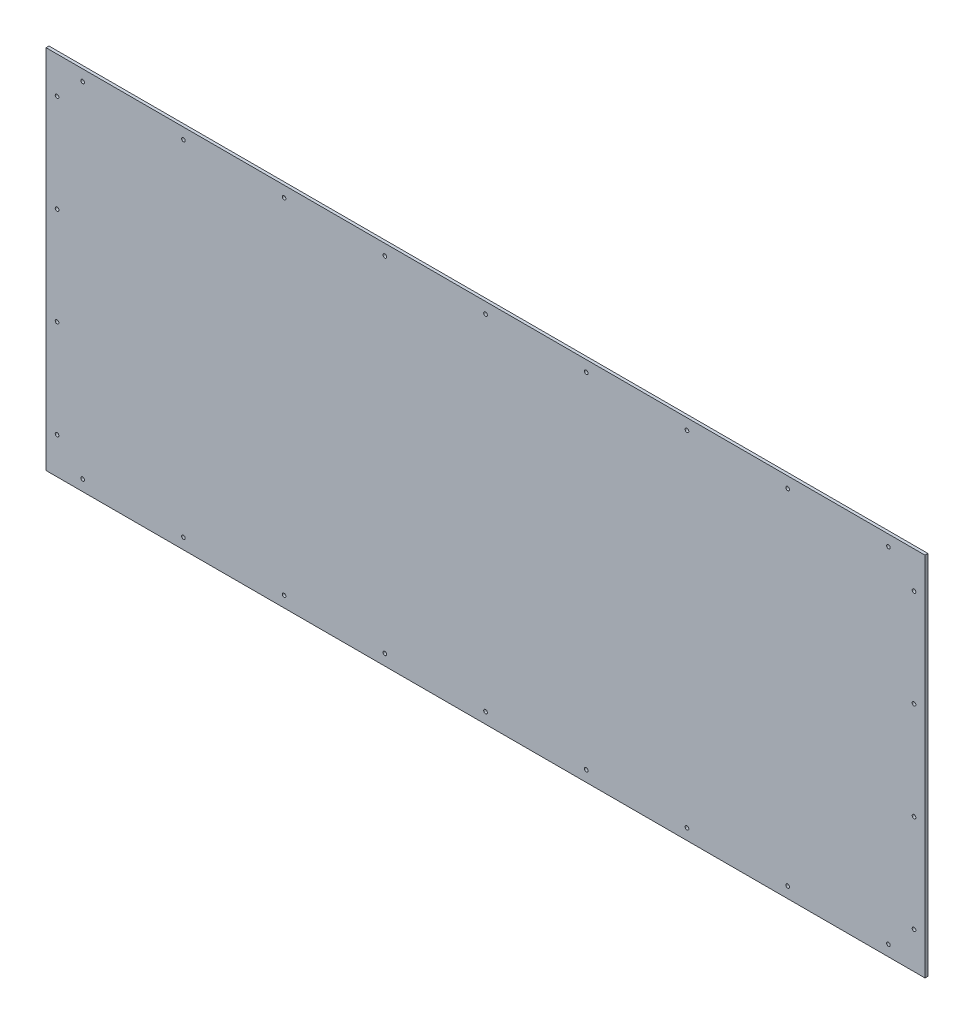
from build123d import *

# Parameters (mm, degrees)
CROQUIS2_W              = 600
CROQUIS2_H              = 250
SALIENTE_EXTRUIR1_DEPTH = 2
CROQUIS5_R              = 1.25
CORTAR_EXTRUIR3_DEPTH   = 3


with BuildPart() as part:
    # Croquis2 → Saliente-Extruir1 (new body)
    with BuildSketch(Plane.XY):
        Rectangle(CROQUIS2_W, CROQUIS2_H)
    extrude(amount=SALIENTE_EXTRUIR1_DEPTH)

    # Croquis5 → Cortar-Extruir3 (cut, through all)
    with BuildSketch(Plane.XY):
        with Locations((-292.5, 100)):
            Circle(CROQUIS5_R)
        with Locations((-292.5, -100)):
            Circle(CROQUIS5_R)
        with Locations((-292.5, 33.333333333)):
            Circle(CROQUIS5_R)
        with Locations((-292.5, -33.333333333)):
            Circle(CROQUIS5_R)
        with Locations((292.5, -33.333333333)):
            Circle(CROQUIS5_R)
        with Locations((292.5, 33.333333333)):
            Circle(CROQUIS5_R)
        with Locations((292.5, -100)):
            Circle(CROQUIS5_R)
        with Locations((292.5, 100)):
            Circle(CROQUIS5_R)
        with Locations((-275, 117.5)):
            Circle(CROQUIS5_R)
        with Locations((-206.25, 117.5)):
            Circle(CROQUIS5_R)
        with Locations((-137.5, 117.5)):
            Circle(CROQUIS5_R)
        with Locations((-68.75, 117.5)):
            Circle(CROQUIS5_R)
        with Locations((68.75, 117.5)):
            Circle(CROQUIS5_R)
        with Locations((137.5, 117.5)):
            Circle(CROQUIS5_R)
        with Locations((206.25, 117.5)):
            Circle(CROQUIS5_R)
        with Locations((275, 117.5)):
            Circle(CROQUIS5_R)
        with Locations((0, 117.5)):
            Circle(CROQUIS5_R)
        with Locations((0, -117.5)):
            Circle(CROQUIS5_R)
        with Locations((275, -117.5)):
            Circle(CROQUIS5_R)
        with Locations((206.25, -117.5)):
            Circle(CROQUIS5_R)
        with Locations((137.5, -117.5)):
            Circle(CROQUIS5_R)
        with Locations((68.75, -117.5)):
            Circle(CROQUIS5_R)
        with Locations((-68.75, -117.5)):
            Circle(CROQUIS5_R)
        with Locations((-137.5, -117.5)):
            Circle(CROQUIS5_R)
        with Locations((-206.25, -117.5)):
            Circle(CROQUIS5_R)
        with Locations((-275, -117.5)):
            Circle(CROQUIS5_R)
    extrude(amount=CORTAR_EXTRUIR3_DEPTH, mode=Mode.SUBTRACT)


solid = part.part
